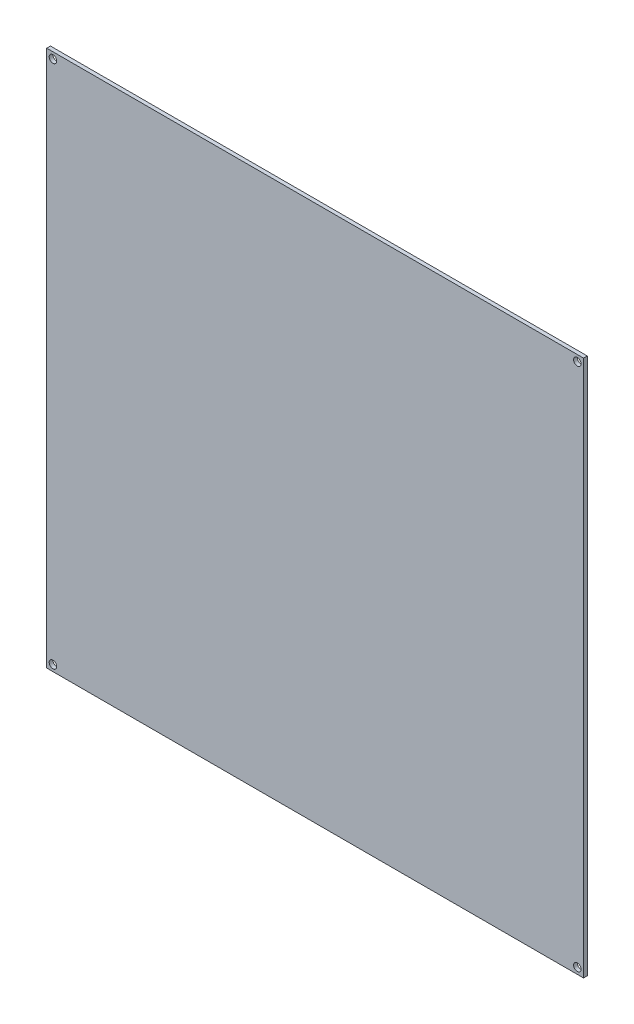
from build123d import *

# Parameters (mm, degrees)
ESBO_O1_W                = 215
ESBO_O1_H                = 215
ESBO_O1_R                = 1.5
RESSALTO_EXTRUS_O1_DEPTH = 1.5


with BuildPart() as part:
    # Esboço1 → Ressalto-extrusão1 (new body)
    with BuildSketch(Plane.XY):
        Rectangle(ESBO_O1_W, ESBO_O1_H)
        with Locations((-105, 105)):
            Circle(ESBO_O1_R, mode=Mode.SUBTRACT)
        with Locations((105, 105)):
            Circle(ESBO_O1_R, mode=Mode.SUBTRACT)
        with Locations((105, -105)):
            Circle(ESBO_O1_R, mode=Mode.SUBTRACT)
        with Locations((-105, -105)):
            Circle(ESBO_O1_R, mode=Mode.SUBTRACT)
    extrude(amount=RESSALTO_EXTRUS_O1_DEPTH)


solid = part.part
